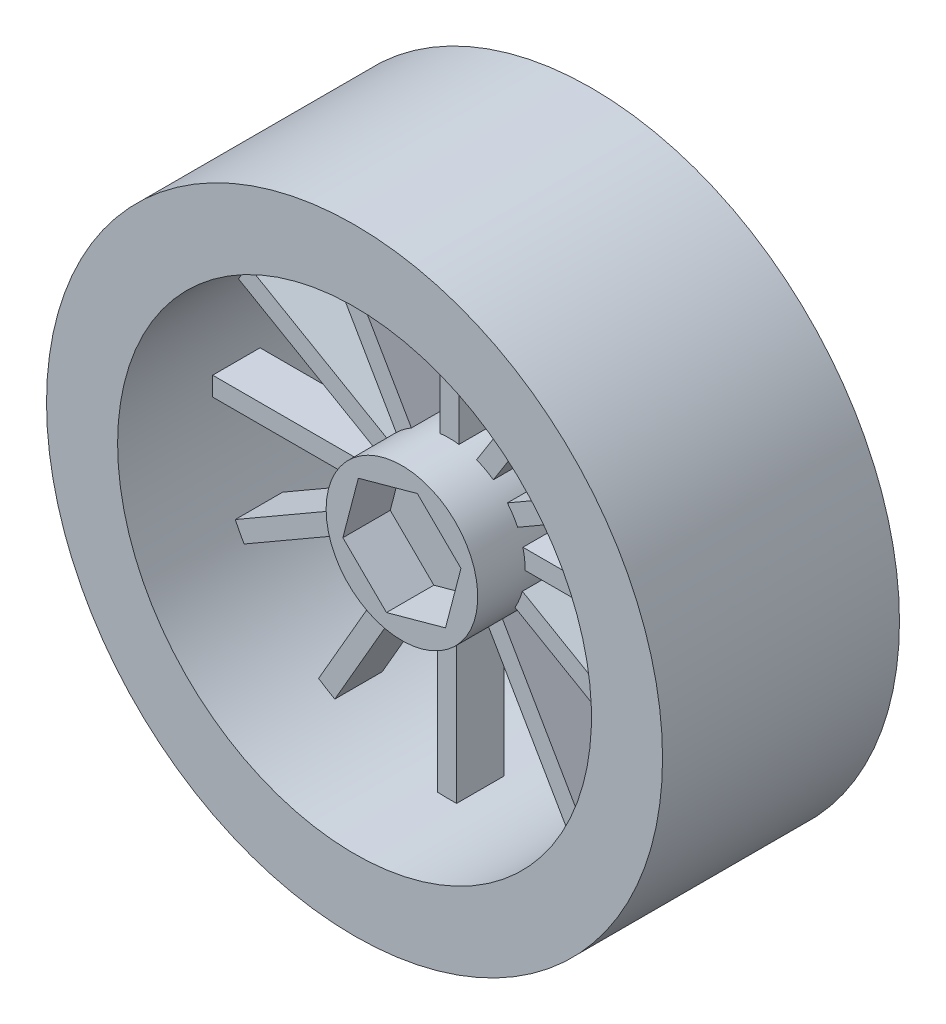
from build123d import *

# Parameters (mm, degrees)
SKETCH_1_R          = 32.5
EXTRUDE_1_DEPTH     = 25
SKETCH_2_R          = 25
CUT_EXTRUDE_1_DEPTH = 25
SKETCH_6_R          = 8
EXTRUDE_3_DEPTH     = 20
SKETCH_7_R          = 8
CUT_EXTRUDE_2_DEPTH = 5
CUT_EXTRUDE_3_DEPTH = 5
CUT_EXTRUDE_4_DEPTH = 5
SKETCH_11_W         = 21
SKETCH_11_H         = 2
EXTRUDE_1_2_DEPTH   = 5
SKETCH_15_W         = 18
SKETCH_15_H         = 2
EXTRUDE_8_DEPTH     = 5
SKETCH_17_W         = 2
SKETCH_17_H         = 19.626417589
EXTRUDE_9_DEPTH     = 5
SKETCH_19_W         = 2
SKETCH_19_H         = 25
EXTRUDE_10_DEPTH    = 5
EXTRUDE_12_DEPTH    = 5
EXTRUDE_13_DEPTH    = 5
EXTRUDE_16_DEPTH    = 5
EXTRUDE_18_DEPTH    = 5
EXTRUDE_20_DEPTH    = 5
EXTRUDE_21_DEPTH    = 5
EXTRUDE_22_DEPTH    = 5
EXTRUDE_23_DEPTH    = 5


with BuildPart() as part:
    # 草图1 → Extrude 1 (new body)
    with BuildSketch(Plane.XY):
        Circle(SKETCH_1_R)
    extrude(amount=EXTRUDE_1_DEPTH)

    # 草图2 → 切除-拉伸1 (cut)
    with BuildSketch(Plane(origin=(0, 0, 0), x_dir=(-1, 0, 0), z_dir=(0, 0, -1))):
        Circle(SKETCH_2_R)
    extrude(amount=-CUT_EXTRUDE_1_DEPTH, mode=Mode.SUBTRACT)



with BuildPart() as body_2:
    # 草图6 → 凸台-拉伸3 (new body)
    with BuildSketch(Plane(origin=(0, 0, 0), x_dir=(-1, 0, 0), z_dir=(0, 0, -1))):
        Circle(SKETCH_6_R)
    extrude(amount=-EXTRUDE_3_DEPTH)

    # 草图7 → 切除-拉伸2 (cut)
    with BuildSketch(Plane(origin=(0, 0, 0), x_dir=(-1, 0, 0), z_dir=(0, 0, -1))):
        Circle(SKETCH_7_R)
    extrude(amount=-CUT_EXTRUDE_2_DEPTH, mode=Mode.SUBTRACT)

    # 草图8 → 切除-拉伸3 (cut)
    with BuildSketch(Plane(origin=(0, 0, 5), x_dir=(-1, 0, 0), z_dir=(0, 0, -1))):
        Polygon((6.204878503, 0), (3.102439251, 5.373582411), (-3.102439251, 5.373582411), (-6.204878503, 0), (-3.102439251, -5.373582411), (3.102439251, -5.373582411), align=None)
    extrude(amount=-CUT_EXTRUDE_3_DEPTH, mode=Mode.SUBTRACT)

    # 草图9 → 切除-拉伸4 (cut)
    with BuildSketch(Plane.XY.offset(20)):
        Polygon((-1.630765345, -6.252377794), (4.599335331, -4.538473114), (6.230100676, 1.713904681), (1.630765345, 6.252377794), (-4.599335331, 4.538473114), (-6.230100676, -1.713904681), align=None)
    extrude(amount=-CUT_EXTRUDE_4_DEPTH, mode=Mode.SUBTRACT)


with BuildPart() as part_1:
    add(part.part)

    add(body_2.part)  # Extrude 1 2 merges body 2
    # 草图11 → Extrude 1 2 (add)
    with BuildSketch(Plane(origin=(0, -0.732123309, 10), x_dir=(-1, 0, 0), z_dir=(0, 0, -1))):
        with Locations((17.554946424, 1)):
            Rectangle(SKETCH_11_W, SKETCH_11_H)
    extrude(amount=-EXTRUDE_1_2_DEPTH)

    # 草图15 → 拉伸-薄壁8 (add)
    with BuildSketch(Plane(origin=(0.783900643, -0.087404702, 10), x_dir=(-1, 0, 0), z_dir=(0, 0, -1))):
        with Locations((-15.204878503, 1)):
            Rectangle(SKETCH_15_W, SKETCH_15_H)
    extrude(amount=-EXTRUDE_8_DEPTH)

    # 草图17 → 拉伸-薄壁9 (add)
    with BuildSketch(Plane(origin=(1.021360023, 0, 10), x_dir=(-1, 0, 0), z_dir=(0, 0, -1))):
        with Locations((1, 15.186791206)):
            Rectangle(SKETCH_17_W, SKETCH_17_H)
    extrude(amount=-EXTRUDE_9_DEPTH)

    # 草图19 → 拉伸-薄壁10 (add)
    with BuildSketch(Plane(origin=(0, 0, 10), x_dir=(-1, 0, 0), z_dir=(0, 0, -1))):
        with Locations((0.222489214, -12.5)):
            Rectangle(SKETCH_19_W, SKETCH_19_H)
    extrude(amount=-EXTRUDE_10_DEPTH)

    # 草图22 → 拉伸-薄壁12 (add)
    with BuildSketch(Plane(origin=(0.523395748, 0, 10), x_dir=(-1, 0, 0), z_dir=(0, 0, -1))):
        Polygon((0, 0), (-13.36975493, 21.124621964), (-11.679785173, 22.194202358), (1.689969757, 1.069580394), align=None)
    extrude(amount=-EXTRUDE_12_DEPTH)

    # 草图23 → 拉伸-薄壁13 (add)
    with BuildSketch(Plane(origin=(0, -0.702264438, 10), x_dir=(-1, 0, 0), z_dir=(0, 0, -1))):
        Polygon((0, 0), (-22.409578035, 12.938175911), (-21.409578035, 14.670226719), (1, 1.732050808), align=None)
    extrude(amount=-EXTRUDE_13_DEPTH)

    # 草图25 → 拉伸-薄壁16 (add)
    with BuildSketch(Plane(origin=(0, 0.899260589, 10), x_dir=(-1, 0, 0), z_dir=(0, 0, -1))):
        Polygon((0, 0), (21.650635095, 12.5), (22.650635095, 10.767949192), (1, -1.732050808), align=None)
    extrude(amount=-EXTRUDE_16_DEPTH)

    # 草图26 → 拉伸-薄壁18 (add)
    with BuildSketch(Plane(origin=(0, 0, 10), x_dir=(-1, 0, 0), z_dir=(0, 0, -1))):
        Polygon((0, 0), (13.491648386, 23.368220483), (15.223699194, 22.368220483), (1.732050808, -1), align=None)
    extrude(amount=-EXTRUDE_18_DEPTH)

    # 草图27 → 拉伸-薄壁20 (add)
    with BuildSketch(Plane(origin=(0, 0, 10), x_dir=(-1, 0, 0), z_dir=(0, 0, -1))):
        Polygon((0, 0), (-23.067411296, -13.317976121), (-24.067411296, -11.585925314), (-1, 1.732050808), align=None)
    extrude(amount=-EXTRUDE_20_DEPTH)

    # 草图28 → 拉伸-薄壁21 (add)
    with BuildSketch(Plane(origin=(0, 0, 10), x_dir=(-1, 0, 0), z_dir=(0, 0, -1))):
        Polygon((0, 0), (-13.731376059, -23.783440992), (-15.463426867, -22.783440992), (-1.732050808, 1), align=None)
    extrude(amount=-EXTRUDE_21_DEPTH)

    # 草图29 → 拉伸-薄壁22 (add)
    with BuildSketch(Plane(origin=(-1.752500167, 0, 10), x_dir=(-1, 0, 0), z_dir=(0, 0, -1))):
        Polygon((0, 0), (13.9695501, -24.195970532), (12.237499292, -25.195970532), (-1.732050808, -1), align=None)
    extrude(amount=-EXTRUDE_22_DEPTH)

    # 草图30 → 拉伸-薄壁23 (add)
    with BuildSketch(Plane.XY.offset(15)):
        Polygon((0, 0), (-22.652441565, -13.078393235), (-23.652441565, -11.346342428), (-1, 1.732050808), align=None)
    extrude(amount=-EXTRUDE_23_DEPTH)


solid = part_1.part
